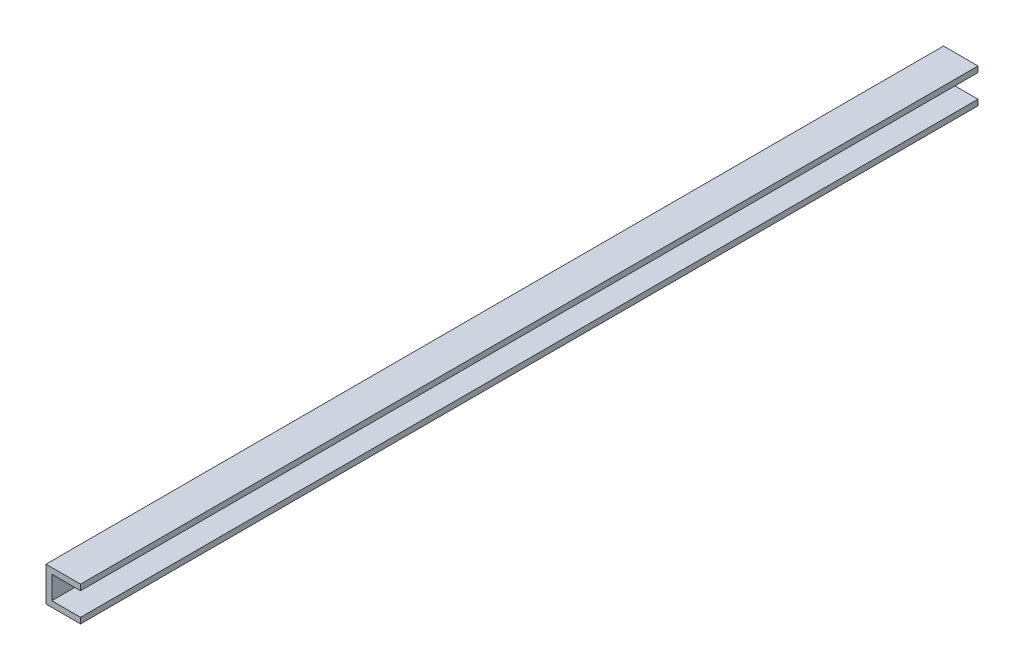
from build123d import *

# Parameters (mm, degrees)
BOSS_EXTRUDE1_DEPTH       = 123.825
SKETCH11_W                = 1.5875
SKETCH11_H                = 4.7625
CUT_EXTRUDE2_DEPTH        = 10.525
F_6_32_TAPPED_HOLE1_D     = 2.7051
F_6_32_TAPPED_HOLE1_DEPTH = 9.398


with BuildPart() as part:
    # Sketch1 → Boss-Extrude1 (new body, symmetric)
    with BuildSketch(Plane.XY):
        Polygon((0, 4.7625), (0, -4.7625), (9.525, -4.7625), (9.525, -3.175), (1.5875, -3.175), (1.5875, 3.175), (9.525, 3.175), (9.525, 4.7625), align=None)
    extrude(amount=BOSS_EXTRUDE1_DEPTH, both=True)

    # Sketch11 → Cut-Extrude2 (cut, through all)
    with BuildSketch(Plane.ZY):
        with Locations((-120.49125, 0)):
            Rectangle(SKETCH11_W, SKETCH11_H)
        with Locations((-114.14125, 0)):
            Rectangle(SKETCH11_W, SKETCH11_H)
    extrude(amount=-CUT_EXTRUDE2_DEPTH, mode=Mode.SUBTRACT)

    # #6-32 Tapped Hole1
    with Locations(Plane.ZY):
        with Locations((-100.6475, 0), (-87.80859375, 0), (-74.9696875, 0), (-62.13078125, 0), (-49.291875, 0), (-36.45296875, 0), (-23.6140625, 0), (-10.77515625, 0), (2.06375, 0), (14.90265625, 0), (27.7415625, 0), (40.58046875, 0), (53.419375, 0), (66.25828125, 0), (79.0971875, 0), (91.93609375, 0)):
            Hole(F_6_32_TAPPED_HOLE1_D / 2, depth=F_6_32_TAPPED_HOLE1_DEPTH)


solid = part.part
